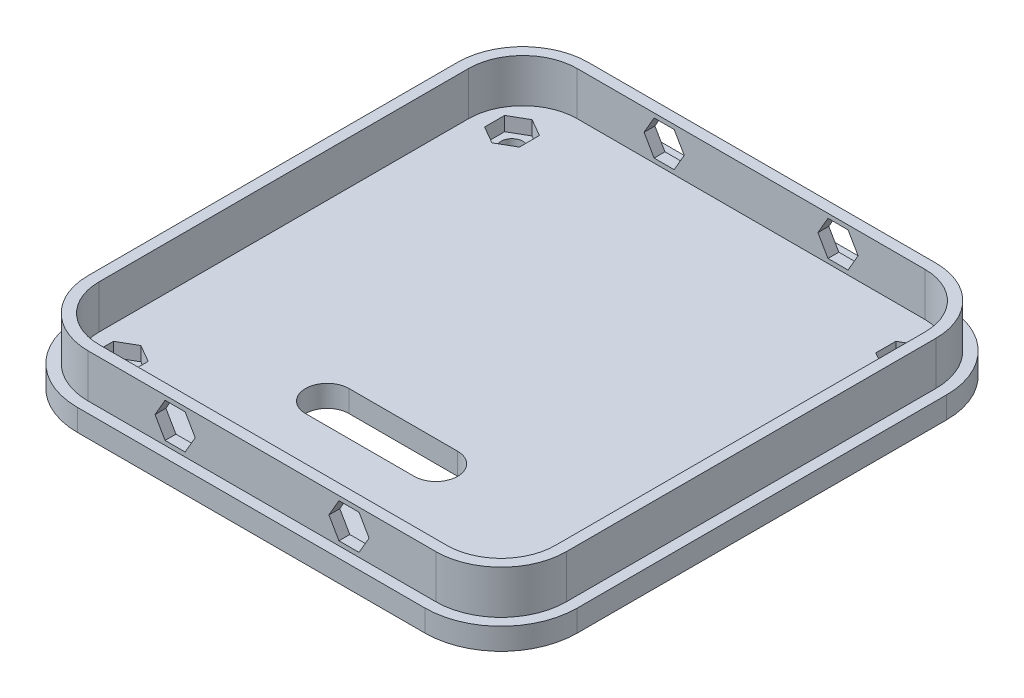
from build123d import *

# Parameters (mm, degrees)
SKETCH1_W           = 220
SKETCH1_H           = 230
BOSS_EXTRUDE1_DEPTH = 20
FILLET1_R           = 30
BOSS_EXTRUDE4_DEPTH = 10
CUT_EXTRUDE10_DEPTH = 20
SKETCH6_R           = 5.025
CUT_EXTRUDE3_DEPTH  = 31
SKETCH8_R           = 5
CUT_EXTRUDE4_DEPTH  = 30
SKETCH7_R           = 5
CUT_EXTRUDE5_DEPTH  = 30
CUT_EXTRUDE6_DEPTH  = 8.5
CUT_EXTRUDE7_DEPTH  = 8.5
CUT_EXTRUDE8_DEPTH  = 26.5
CUT_EXTRUDE9_DEPTH  = 31


with BuildPart() as part:
    # Sketch1 → Boss-Extrude1 (new body)
    with BuildSketch(Plane(origin=(0, 0, 0), x_dir=(1, 0, 0), z_dir=(0, 1, 0))):
        with Locations((110, 115)):
            Rectangle(SKETCH1_W, SKETCH1_H)
    extrude(amount=BOSS_EXTRUDE1_DEPTH)

    # Fillet1
    fillet1_edges = [part.edges().sort_by_distance(p)[0] for p in [
        (0, 10, -230),
        (220, 10, -230),
        (220, 10, 0),
        (0, 10, 0),
    ]]
    fillet(fillet1_edges, radius=FILLET1_R)

    # Sketch4 → Boss-Extrude4 (add)
    with BuildSketch(Plane(origin=(0, 0, 0), x_dir=(-1, 0, 0), z_dir=(0, -1, 0))):
        with BuildLine():
            Line((-225, 200), (-225, 30))
            ThreePointArc((-225, 30), (-214.748737342, 5.251262658), (-190, -5))
            Line((-190, -5), (-30, -5))
            ThreePointArc((-30, -5), (-5.251262658, 5.251262658), (5, 30))
            Line((5, 30), (5, 200))
            ThreePointArc((5, 200), (-5.251262658, 224.748737342), (-30, 235))
            Line((-30, 235), (-190, 235))
            ThreePointArc((-190, 235), (-214.748737342, 224.748737342), (-225, 200))
        make_face()
    extrude(amount=BOSS_EXTRUDE4_DEPTH)

    # Sketch15 → Cut-Extrude10 (cut)
    with BuildSketch(Plane(origin=(0, 20, 0), x_dir=(1, 0, 0), z_dir=(0, 1, 0))):
        with BuildLine():
            Line((215, 30), (215, 200))
            ThreePointArc((215, 200), (207.67766953, 217.67766953), (190, 225))
            Line((190, 225), (30, 225))
            ThreePointArc((30, 225), (12.32233047, 217.67766953), (5, 200))
            Line((5, 200), (5, 30))
            ThreePointArc((5, 30), (12.32233047, 12.32233047), (30, 5))
            Line((30, 5), (190, 5))
            ThreePointArc((190, 5), (207.67766953, 12.32233047), (215, 30))
        make_face()
    extrude(amount=-CUT_EXTRUDE10_DEPTH, mode=Mode.SUBTRACT)

    # Sketch6 → Cut-Extrude3 (cut, through all)
    with BuildSketch(Plane(origin=(0, -10, 0), x_dir=(-1, 0, 0), z_dir=(0, -1, 0))):
        with Locations((-200, 205)):
            Circle(SKETCH6_R)
        with Locations((-20, 205)):
            Circle(SKETCH6_R)
        with Locations((-20, 25)):
            Circle(SKETCH6_R)
        with Locations((-200, 25)):
            Circle(SKETCH6_R)
    extrude(amount=-CUT_EXTRUDE3_DEPTH, mode=Mode.SUBTRACT)

    # Sketch8 → Cut-Extrude4 (cut)
    with BuildSketch(Plane(origin=(0, 0, -230), x_dir=(-1, 0, 0), z_dir=(0, 0, -1))):
        with Locations((-150, 10)):
            Circle(SKETCH8_R)
        with Locations((-70, 10)):
            Circle(SKETCH8_R)
    extrude(amount=-CUT_EXTRUDE4_DEPTH, mode=Mode.SUBTRACT)

    # Sketch7 → Cut-Extrude5 (cut)
    with BuildSketch(Plane.XY):
        with Locations((70, 10)):
            Circle(SKETCH7_R)
        with Locations((150, 10)):
            Circle(SKETCH7_R)
    extrude(amount=-CUT_EXTRUDE5_DEPTH, mode=Mode.SUBTRACT)

    # Sketch10 → Cut-Extrude6 (cut)
    with BuildSketch(Plane(origin=(0, 0, -230), x_dir=(-1, 0, 0), z_dir=(0, 0, -1))):
        Polygon((-159.237604307, 10), (-154.618802154, 2), (-145.381197846, 2), (-140.762395693, 10), (-145.381197846, 18), (-154.618802154, 18), align=None)
        Polygon((-79.237604307, 10), (-74.618802154, 2), (-65.381197846, 2), (-60.762395693, 10), (-65.381197846, 18), (-74.618802154, 18), align=None)
    extrude(amount=-CUT_EXTRUDE6_DEPTH, mode=Mode.SUBTRACT)

    # Sketch9 → Cut-Extrude7 (cut)
    with BuildSketch(Plane.XY):
        Polygon((60.762395693, 10), (65.381197846, 2), (74.618802154, 2), (79.237604307, 10), (74.618802154, 18), (65.381197846, 18), align=None)
        Polygon((154.618802154, 2), (145.381197846, 2), (140.762395693, 10), (145.381197846, 18), (154.618802154, 18), (159.237604307, 10), align=None)
    extrude(amount=-CUT_EXTRUDE7_DEPTH, mode=Mode.SUBTRACT)

    # Sketch11 → Cut-Extrude8 (cut)
    with BuildSketch(Plane(origin=(0, 20, 0), x_dir=(1, 0, 0), z_dir=(0, 1, 0))):
        Polygon((20, 214.237604307), (12, 209.618802154), (12, 200.381197846), (20, 195.762395693), (28, 200.381197846), (28, 209.618802154), align=None)
        Polygon((192, 209.618802154), (200, 214.237604307), (208, 209.618802154), (208, 200.381197846), (200, 195.762395693), (192, 200.381197846), align=None)
        Polygon((192, 29.618802154), (192, 20.381197846), (200, 15.762395693), (208, 20.381197846), (208, 29.618802154), (200, 34.237604307), align=None)
        Polygon((28, 20.381197846), (20, 15.762395693), (12, 20.381197846), (12, 29.618802154), (20, 34.237604307), (28, 29.618802154), align=None)
    extrude(amount=-CUT_EXTRUDE8_DEPTH, mode=Mode.SUBTRACT)

    # Sketch13 → Cut-Extrude9 (cut, through all)
    with BuildSketch(Plane.XZ.offset(10)):
        with BuildLine():
            Line((135, -65), (85, -65))
            ThreePointArc((85, -65), (75, -55), (85, -45))
            Line((85, -45), (135, -45))
            ThreePointArc((135, -45), (145, -55), (135, -65))
        make_face()
    extrude(amount=-CUT_EXTRUDE9_DEPTH, mode=Mode.SUBTRACT)


solid = part.part
